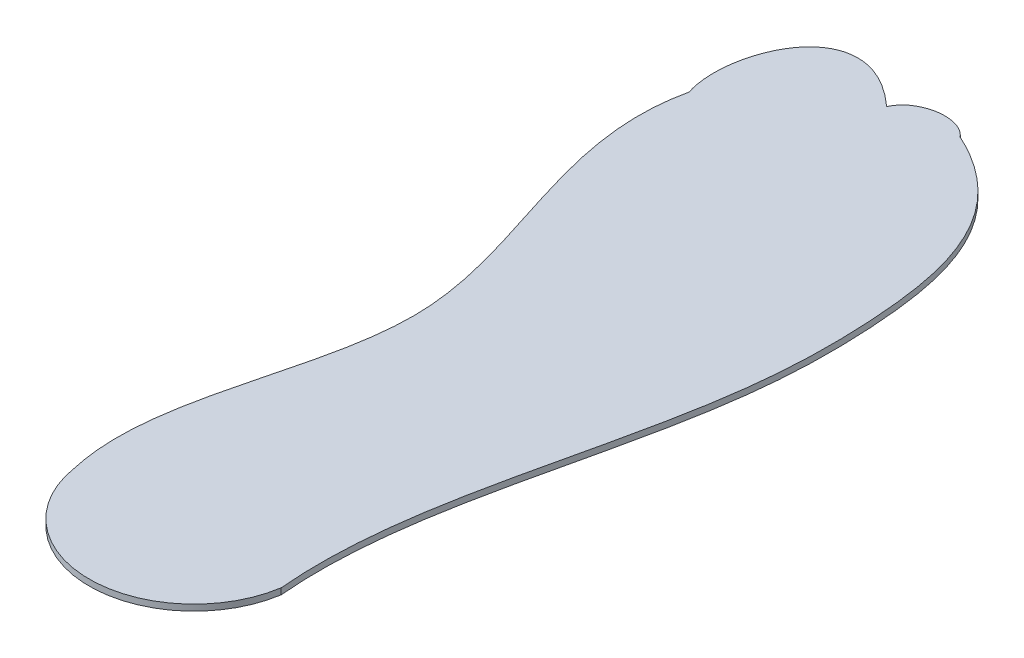
from build123d import *

# Parameters (mm, degrees)
BOSS_EXTRUDE1_DEPTH = 2


with BuildPart() as part:
    # Sketch1 → Boss-Extrude1 (new body)
    with BuildSketch(Plane(origin=(0, 0, 0), x_dir=(1, 0, 0), z_dir=(0, 1, 0))):
        with BuildLine():
            ThreePointArc((-40.679244353, -103.221523445), (-6.884583356, -132.122739902), (26.910077355, -103.221523111))
            add(Edge.make_bspline(
                [(10.32075615, 135.087420221), (39.402555208, 121.787875107), (48.095792581, 85.931785161), (48.363582245, 1.743673196), (22.570320599, -55.244701587), (26.910077355, -103.221523111)],
                knots=[0, 0, 0, 0, 0.296821126, 0.429544144, 1, 1, 1, 1], degree=3))
            add(Edge.make_bspline(
                [(-10.296198393, 131.704373688), (-7.252650356, 138.974935501), (5.280450445, 141.193491305), (10.32075615, 135.087420221)],
                knots=[0, 0, 0, 0, 1, 1, 1, 1], degree=3))
            add(Edge.make_bspline(
                [(-46.679244317, 103.587421062), (-52.785760987, 121.907427011), (-38.636955581, 157.574381944), (-10.296198393, 131.704373688)],
                knots=[0, 0, 0, 0, 1, 1, 1, 1], degree=3))
            add(Edge.make_bspline(
                [(-40.679244353, -103.221523445), (-48.424660229, -69.464624821), (-5.31250584, -0.275920012), (-54.797034308, 67.469917015), (-46.679244317, 103.587421062)],
                knots=[0, 0, 0, 0, 0.483382248, 1, 1, 1, 1], degree=3))
        make_face()
    extrude(amount=BOSS_EXTRUDE1_DEPTH)


solid = part.part
